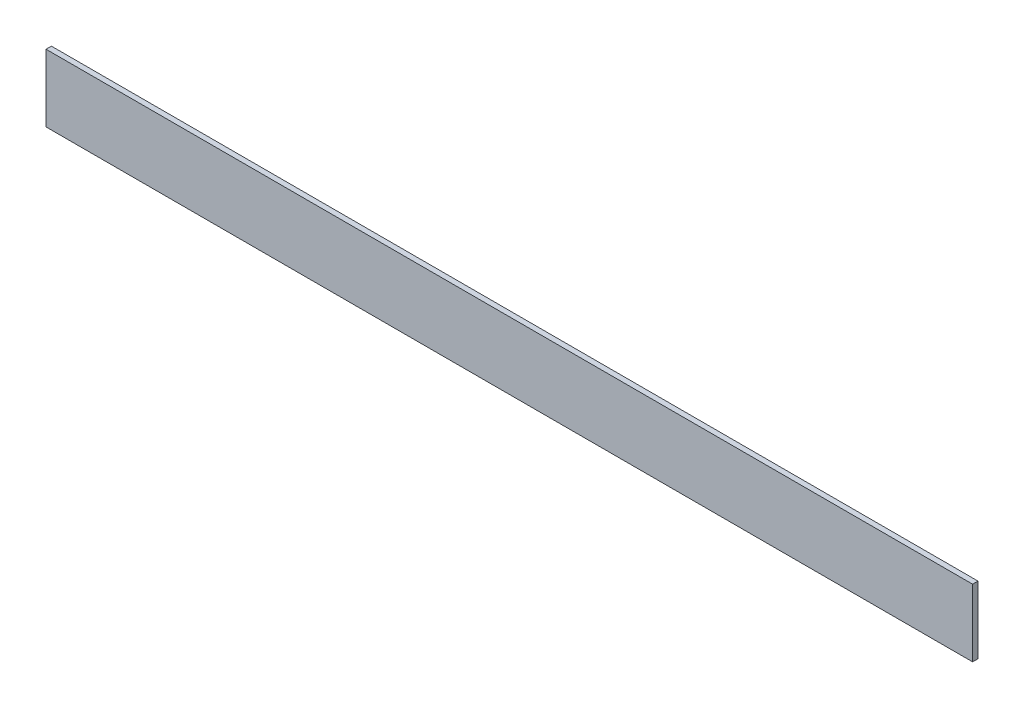
from build123d import *

# Parameters (mm, degrees)
SKETCH_2_W      = 2
SKETCH_2_H      = 25
EXTRUDE_1_DEPTH = 344.2


with BuildPart() as part:
    # Эскиз2 → Бобышка-Вытянуть1 (new body)
    with BuildSketch(Plane(origin=(0, 0, 0), x_dir=(0, 0, -1), z_dir=(1, 0, 0))):
        with Locations((1, 12.5)):
            Rectangle(SKETCH_2_W, SKETCH_2_H)
    extrude(amount=EXTRUDE_1_DEPTH)


solid = part.part
